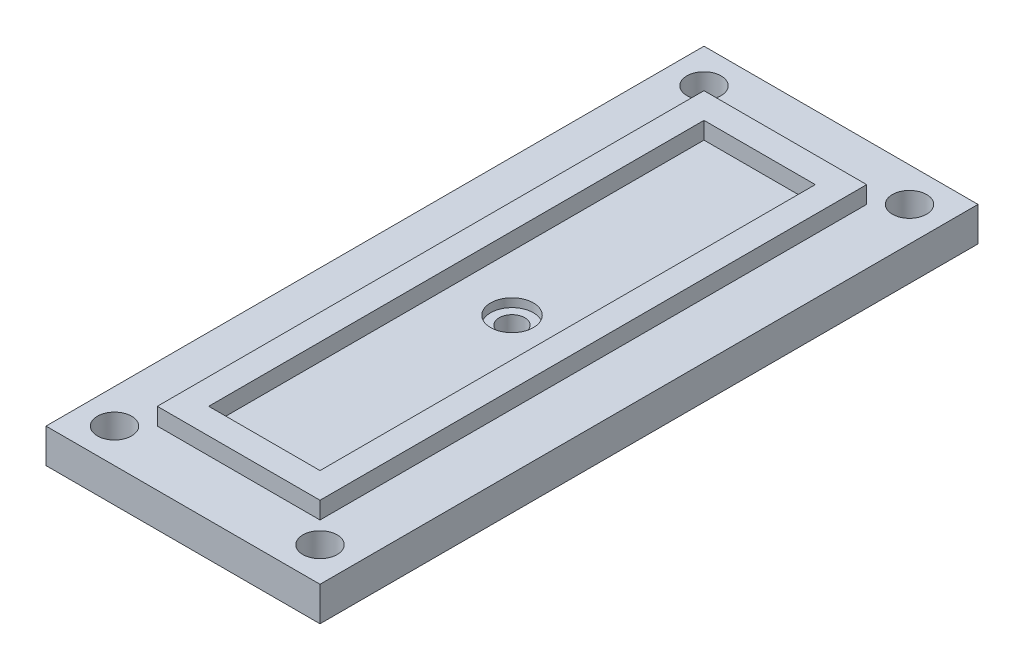
from build123d import *

# Parameters (mm, degrees)
SKETCH1_W               = 16
SKETCH1_H               = 38.42
BOSS_EXTRUDE1_DEPTH     = 2
SKETCH2_W               = 9.5
SKETCH2_H               = 31.92
SKETCH2_W_2             = 6.5
SKETCH2_H_2             = 28.92
EXTRUDE_THIN1_DEPTH     = 1
SKETCH3_R               = 1
CUT_EXTRUDE1_DEPTH      = 4
MIRROR2_COPY_1_SKETCH_R = 1
MIRROR2_COPY_1_DEPTH    = 4
SKETCH5_R               = 0.75
CUT_EXTRUDE2_DEPTH      = 2
CUT_EXTRUDE2_DEPTH_BACK = 3
SKETCH6_R               = 1.25
CUT_EXTRUDE6_DEPTH      = 0.5
SKETCH7_R               = 1.5
BOSS_EXTRUDE2_DEPTH     = 1
SKETCH9_R               = 0.25
CUT_EXTRUDE7_DEPTH      = 2


with BuildPart() as part:
    # Sketch1 → Boss-Extrude1 (new body)
    with BuildSketch(Plane(origin=(0, 0, 0), x_dir=(1, 0, 0), z_dir=(0, 1, 0))):
        Rectangle(SKETCH1_W, SKETCH1_H)
    extrude(amount=BOSS_EXTRUDE1_DEPTH)

    # Sketch2 → Extrude-Thin1 (add)
    with BuildSketch(Plane(origin=(0, 2, 0), x_dir=(1, 0, 0), z_dir=(0, 1, 0))):
        Rectangle(SKETCH2_W, SKETCH2_H)
        Rectangle(SKETCH2_W_2, SKETCH2_H_2, mode=Mode.SUBTRACT)
    extrude(amount=EXTRUDE_THIN1_DEPTH)

    # Sketch3 → Cut-Extrude1 (cut, through all)
    with BuildSketch(Plane.XZ):
        with Locations((6, 17.21)):
            Circle(SKETCH3_R)
    cut_extrude1 = extrude(amount=-CUT_EXTRUDE1_DEPTH, mode=Mode.SUBTRACT)

    # Mirror1: Cut-Extrude1 across plane
    add(cut_extrude1.mirror(Plane(origin=(0, 0, 0), x_dir=(1, 0, 0), z_dir=(0, 0, -1))), mode=Mode.SUBTRACT)

    # Mirror2: Cut-Extrude1 across plane
    add(cut_extrude1.mirror(Plane.ZY), mode=Mode.SUBTRACT)

    # Mirror2 copy 1 sketch → Mirror2 copy 1 (cut, through all)
    with BuildSketch(Plane(origin=(0, 0, 0), x_dir=(-1, 0, 0), z_dir=(0, -1, 0))):
        with Locations((6, 17.21)):
            Circle(MIRROR2_COPY_1_SKETCH_R)
    extrude(amount=-MIRROR2_COPY_1_DEPTH, mode=Mode.SUBTRACT)

    # Sketch5 → Cut-Extrude2 (cut, two sides)
    with BuildSketch(Plane(origin=(0, 2, 0), x_dir=(1, 0, 0), z_dir=(0, 1, 0))) as cut_extrude2_sk:
        Circle(SKETCH5_R)
    extrude(amount=CUT_EXTRUDE2_DEPTH, mode=Mode.SUBTRACT)
    extrude(cut_extrude2_sk.sketch, amount=-CUT_EXTRUDE2_DEPTH_BACK, mode=Mode.SUBTRACT)

    # Sketch6 → Cut-Extrude6 (cut)
    with BuildSketch(Plane(origin=(0, 2, 0), x_dir=(1, 0, 0), z_dir=(0, 1, 0))):
        Circle(SKETCH6_R)
    extrude(amount=-CUT_EXTRUDE6_DEPTH, mode=Mode.SUBTRACT)

    # Sketch7 → Boss-Extrude2 (add)
    with BuildSketch(Plane.XZ):
        Circle(SKETCH7_R)
    extrude(amount=BOSS_EXTRUDE2_DEPTH)

    # Sketch9 → Cut-Extrude7 (cut)
    with BuildSketch(Plane.XZ.offset(1)):
        Circle(SKETCH9_R)
    extrude(amount=-CUT_EXTRUDE7_DEPTH, mode=Mode.SUBTRACT)


solid = part.part
